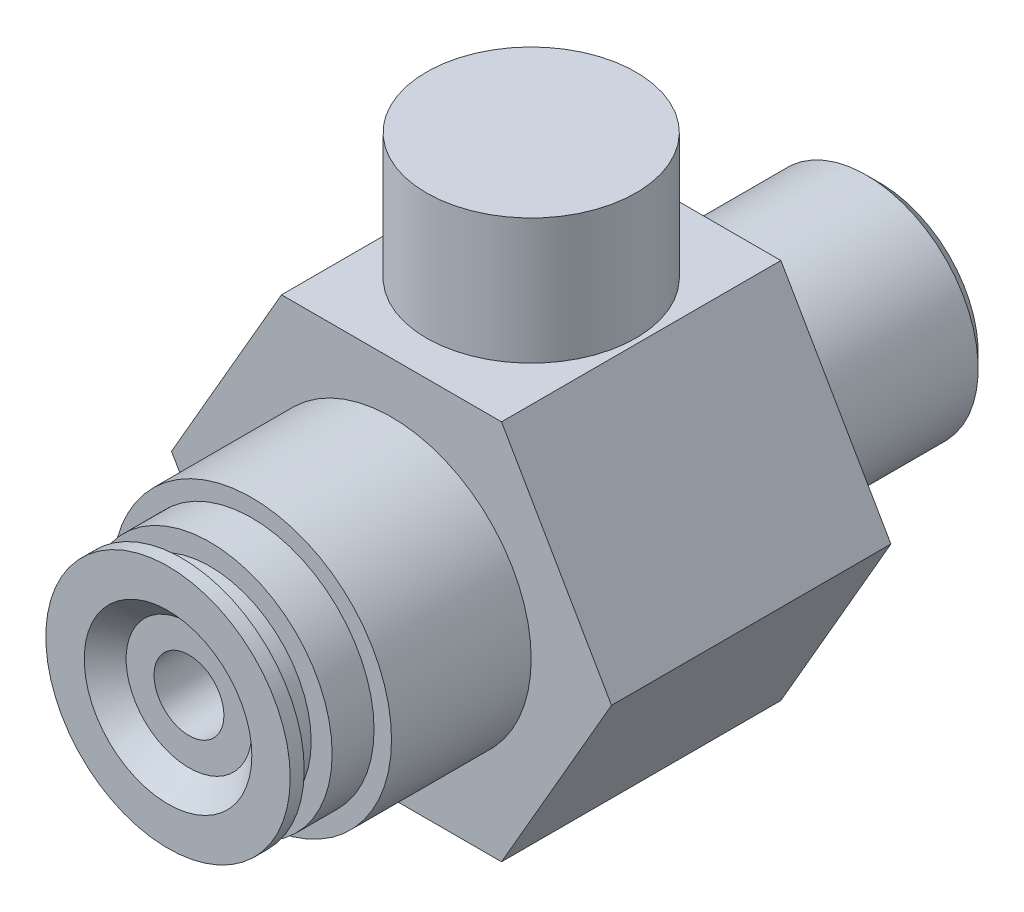
from build123d import *

# Parameters (mm, degrees)
BOSS_EXTRUDE1_DEPTH = 20
SKETCH2_R           = 10
BOSS_EXTRUDE2_DEPTH = 10
SKETCH3_R           = 8.75
BOSS_EXTRUDE3_DEPTH = 6
SKETCH5_R           = 2.5
CUT_EXTRUDE1_DEPTH  = 18.5
SKETCH6_W           = 1.5
SKETCH6_H           = 2
SKETCH7_R           = 4
BOSS_EXTRUDE4_DEPTH = 4
CUT_EXTRUDE2_DEPTH  = 4
SKETCH9_R           = 7.5
BOSS_EXTRUDE5_DEPTH = 9
SKETCH10_R          = 8
SKETCH10_R_2        = 5
BOSS_EXTRUDE6_DEPTH = 15
CHAMFER1_SIZE       = 1


with BuildPart() as part:
    # Sketch1 → Boss-Extrude1 (new body)
    with BuildSketch(Plane.XY):
        Polygon((-7.875, 13.63990011), (7.875, 13.63990011), (15.75, 0), (7.875, -13.63990011), (-7.875, -13.63990011), (-15.75, 0), align=None)
    extrude(amount=BOSS_EXTRUDE1_DEPTH)

    # Sketch2 → Boss-Extrude2 (add)
    with BuildSketch(Plane.XY.offset(20)):
        Circle(SKETCH2_R)
    extrude(amount=BOSS_EXTRUDE2_DEPTH)

    # Sketch3 → Boss-Extrude3 (add)
    with BuildSketch(Plane.XY.offset(30)):
        Circle(SKETCH3_R)
    extrude(amount=BOSS_EXTRUDE3_DEPTH)

    # Sketch4 → Cut-Revolve1 (revolve, cut)
    with BuildSketch(Plane(origin=(0, 0, 0), x_dir=(1, 0, 0), z_dir=(0, 1, 0))):
        Polygon((0, -36), (-6, -36), (-4.5, -34.5), (0, -34.5), align=None)
    revolve(axis=Axis((0, 0, 45.254539395), (0, 0, -1)), mode=Mode.SUBTRACT)

    # Sketch5 → Cut-Extrude1 (cut)
    with BuildSketch(Plane.XY.offset(34.5)):
        Circle(SKETCH5_R)
    extrude(amount=-CUT_EXTRUDE1_DEPTH, mode=Mode.SUBTRACT)

    # Sketch6 → Cut-Revolve2 (revolve, cut)
    with BuildSketch(Plane(origin=(0, 0, 0), x_dir=(1, 0, 0), z_dir=(0, 1, 0))):
        with Locations((-8, -34)):
            Rectangle(SKETCH6_W, SKETCH6_H)
    revolve(axis=Axis((0, 0, 40.657268224), (0, 0, -1)), mode=Mode.SUBTRACT)

    # Sketch7 → Boss-Extrude4 (add)
    with BuildSketch(Plane.XZ.offset(13.63990011)):
        with Locations((0, 10)):
            Circle(SKETCH7_R)
    extrude(amount=BOSS_EXTRUDE4_DEPTH)

    # Sketch8 → Cut-Extrude2 (cut)
    with BuildSketch(Plane.XZ.offset(17.63990011)):
        with BuildLine():
            ThreePointArc((-3, 12.645751311), (-4, 10), (-3, 7.354248689))
            Line((-3, 7.354248689), (-3, 12.645751311))
        make_face()
        with BuildLine():
            Line((3, 12.645751311), (3, 7.354248689))
            ThreePointArc((3, 7.354248689), (3.741657387, 8.585786438), (4, 10))
            ThreePointArc((4, 10), (3.741657387, 11.414213562), (3, 12.645751311))
        make_face()
    extrude(amount=-CUT_EXTRUDE2_DEPTH, mode=Mode.SUBTRACT)

    # Sketch9 → Boss-Extrude5 (add)
    with BuildSketch(Plane(origin=(0, 13.63990011, 0), x_dir=(1, 0, 0), z_dir=(0, 1, 0))):
        with Locations((0, -10)):
            Circle(SKETCH9_R)
    extrude(amount=BOSS_EXTRUDE5_DEPTH)

    # Sketch10 → Boss-Extrude6 (add)
    with BuildSketch(Plane(origin=(0, 0, 0), x_dir=(-1, 0, 0), z_dir=(0, 0, -1))):
        Circle(SKETCH10_R)
        Circle(SKETCH10_R_2, mode=Mode.SUBTRACT)
    extrude(amount=BOSS_EXTRUDE6_DEPTH)

    # Chamfer1
    chamfer1_edges = [part.edges().sort_by_distance(p)[0] for p in [
        (8, 0, -15),
    ]]
    chamfer(chamfer1_edges, length=CHAMFER1_SIZE)


solid = part.part
